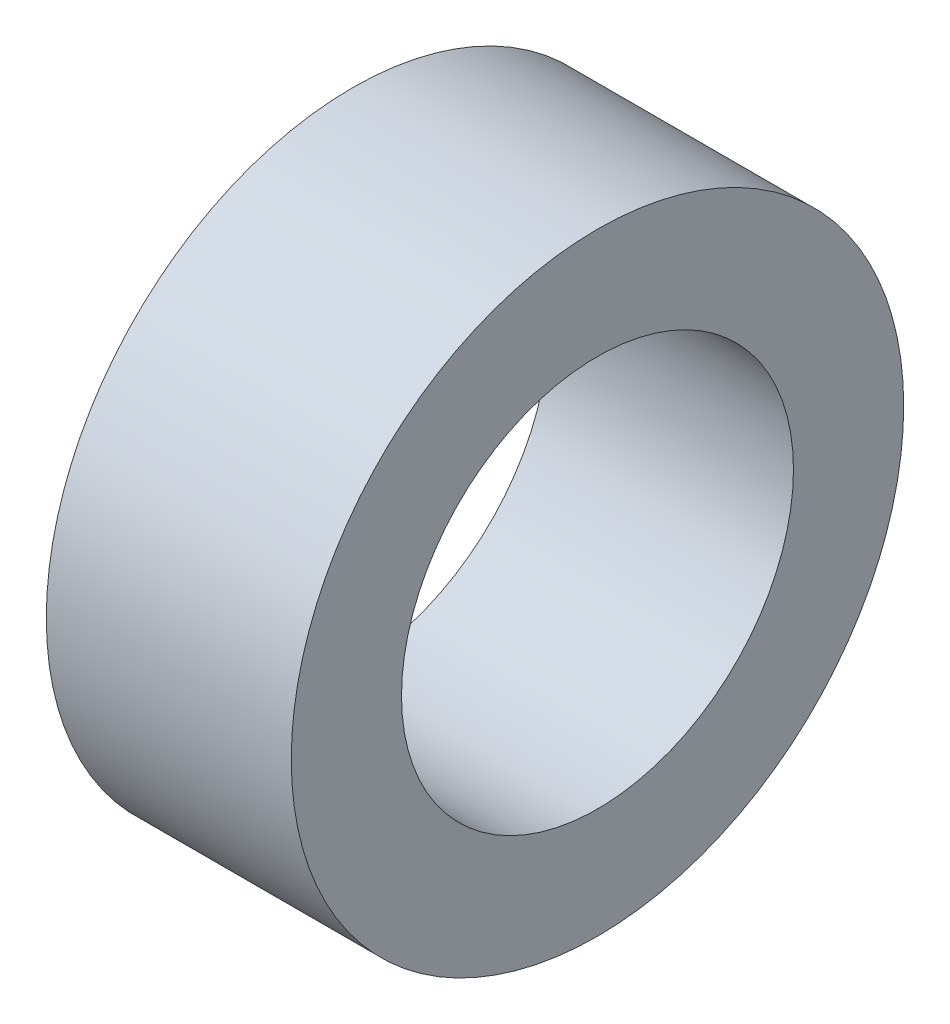
from build123d import *

# Parameters (mm, degrees)
SKETCH1_R           = 2.5
SKETCH1_R_2         = 1.6
BOSS_EXTRUDE1_DEPTH = 2


with BuildPart() as part:
    # Sketch1 → Boss-Extrude1 (new body)
    with BuildSketch(Plane(origin=(0, 0, 0), x_dir=(0, 0, -1), z_dir=(1, 0, 0))):
        Circle(SKETCH1_R)
        Circle(SKETCH1_R_2, mode=Mode.SUBTRACT)
    extrude(amount=BOSS_EXTRUDE1_DEPTH)


solid = part.part
